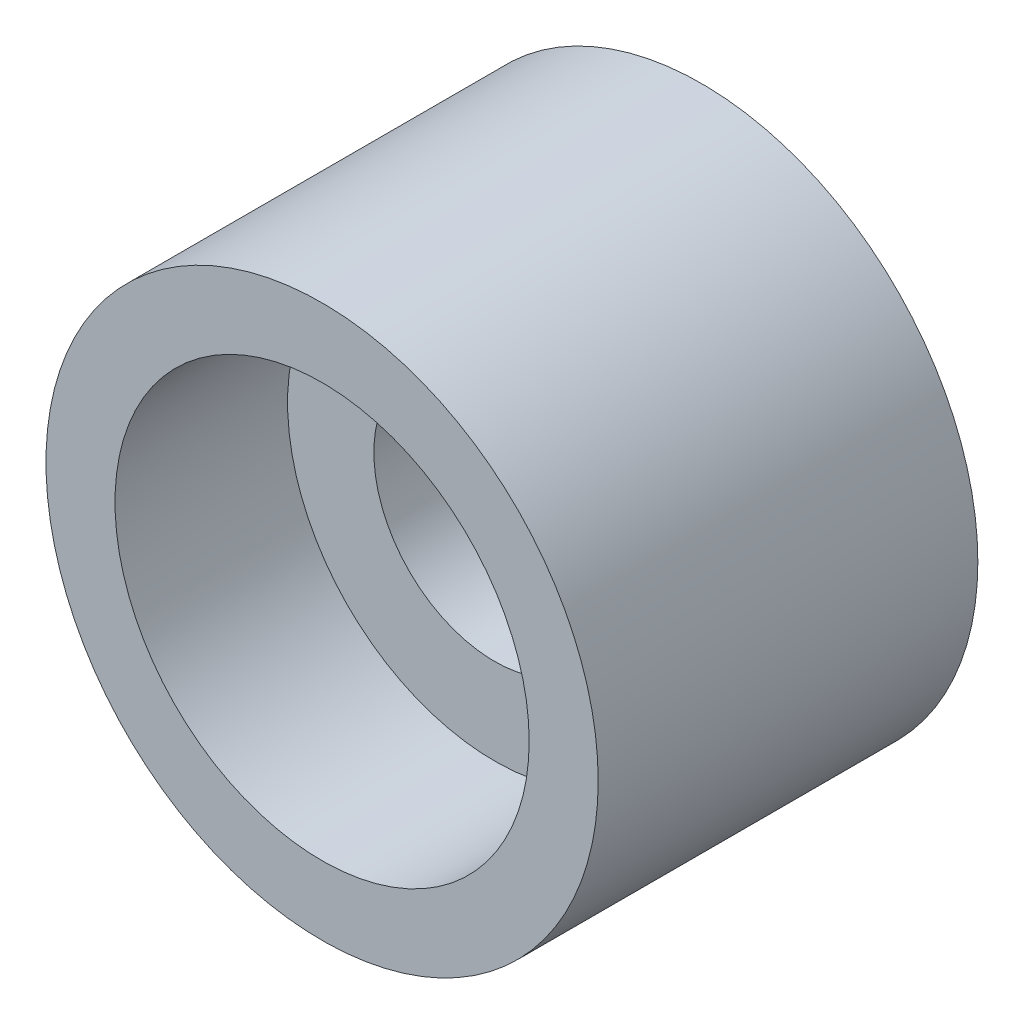
from build123d import *

# Parameters (mm, degrees)
SKETCH1_R                        = 4
SKETCH1_R_2                      = 1.75
BOSS_EXTRUDE1_DEPTH              = 3
SKETCH2_R                        = 4
SKETCH2_R_2                      = 3
BOSS_EXTRUDE2_DEPTH              = 2.5
TAP_DRILL_FOR_M2X0_4_TAP1_REACH  = 11.852
TAP_DRILL_FOR_M2X0_4_TAP1_BORE_R = 0.8


with BuildPart() as part:
    # Sketch1 → Boss-Extrude1 (new body)
    with BuildSketch(Plane.XY):
        Circle(SKETCH1_R)
        Circle(SKETCH1_R_2, mode=Mode.SUBTRACT)
    extrude(amount=BOSS_EXTRUDE1_DEPTH)

    # Sketch2 → Boss-Extrude2 (add)
    with BuildSketch(Plane.XY.offset(3)):
        Circle(SKETCH2_R)
        Circle(SKETCH2_R_2, mode=Mode.SUBTRACT)
    extrude(amount=BOSS_EXTRUDE2_DEPTH)

    # Tap Drill for M2x0.4 Tap1 bore (on position points) → Tap Drill for M2x0.4 Tap1 (cut, up to next)
    with BuildSketch(Plane(origin=(0.135818607, -3.997693498, 1.5), x_dir=(-0.999423374561, -0.033954651826, 0), z_dir=(0.033954651826, -0.999423374561, 0)), mode=Mode.PRIVATE) as tap_drill_for_m2x0_4_tap1_sk1:
        Circle(TAP_DRILL_FOR_M2X0_4_TAP1_BORE_R)
    tap_drill_for_m2x0_4_tap1_tool1 = extrude(tap_drill_for_m2x0_4_tap1_sk1.sketch, amount=-TAP_DRILL_FOR_M2X0_4_TAP1_REACH, mode=Mode.PRIVATE) & part.part
    add(tap_drill_for_m2x0_4_tap1_tool1.solids().sort_by_distance((0.135819, -3.997693, 1.5))[0], mode=Mode.SUBTRACT)


solid = part.part
